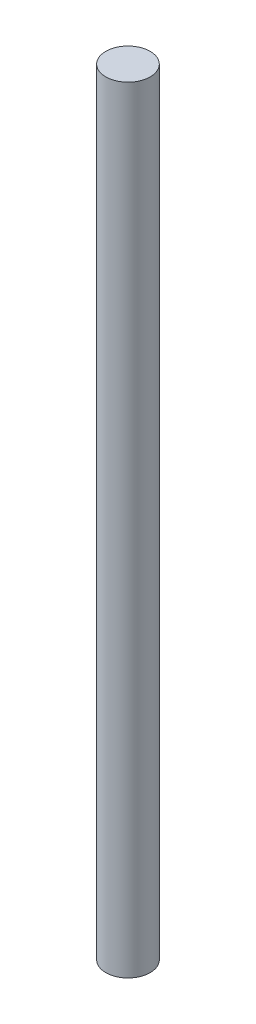
from build123d import *

# Parameters (mm, degrees)
SKETCH1_R           = 2
BOSS_EXTRUDE1_DEPTH = 70


with BuildPart() as part:
    # Sketch1 → Boss-Extrude1 (new body)
    with BuildSketch(Plane(origin=(0, 0, 0), x_dir=(1, 0, 0), z_dir=(0, 1, 0))):
        Circle(SKETCH1_R)
    extrude(amount=BOSS_EXTRUDE1_DEPTH)


solid = part.part
